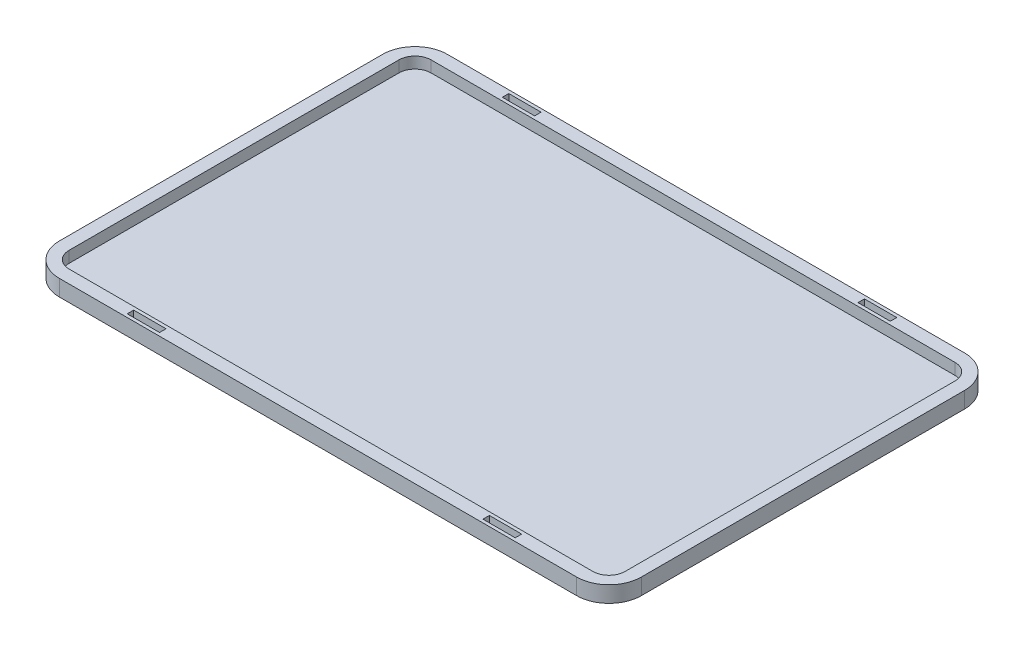
from build123d import *

# Parameters (mm, degrees)
SKETCH1_W           = 180
SKETCH1_H           = 120
BOSS_EXTRUDE1_DEPTH = 5
FILLET1_R           = 10
FILLET2_R           = 10
FILLET3_R           = 10
FILLET4_R           = 10
SHELL1_T            = -4
SKETCH6_W           = 172
SKETCH6_H           = 112
CUT_EXTRUDE1_DEPTH  = 8.5
FILLET5_R           = 5
FILLET6_R           = 5
FILLET7_R           = 5
FILLET8_R           = 5
SKETCH8_W           = 10
SKETCH8_H           = 2
CUT_EXTRUDE2_DEPTH  = 8


with BuildPart() as part:
    # Sketch1 → Boss-Extrude1 (new body)
    with BuildSketch(Plane(origin=(0, 0, 0), x_dir=(1, 0, 0), z_dir=(0, 1, 0))):
        Rectangle(SKETCH1_W, SKETCH1_H)
    extrude(amount=BOSS_EXTRUDE1_DEPTH)

    # Fillet1
    fillet1_edges = [part.edges().sort_by_distance(p)[0] for p in [
        (-90, 2.5, 60),
    ]]
    fillet(fillet1_edges, radius=FILLET1_R)

    # Fillet2
    fillet2_edges = [part.edges().sort_by_distance(p)[0] for p in [
        (90, 2.5, 60),
    ]]
    fillet(fillet2_edges, radius=FILLET2_R)

    # Fillet3
    fillet3_edges = [part.edges().sort_by_distance(p)[0] for p in [
        (90, 2.5, -60),
    ]]
    fillet(fillet3_edges, radius=FILLET3_R)

    # Fillet4
    fillet4_edges = [part.edges().sort_by_distance(p)[0] for p in [
        (-90, 2.5, -60),
    ]]
    fillet(fillet4_edges, radius=FILLET4_R)

    # Shell1
    shell1_openings = [part.faces().sort_by_distance(p)[0] for p in [
        (0, 5, 0),
    ]]
    offset(amount=SHELL1_T, openings=shell1_openings, kind=Kind.INTERSECTION)

    # Sketch6 → Cut-Extrude1 (cut)
    with BuildSketch(Plane(origin=(0, 10, 0), x_dir=(1, 0, 0), z_dir=(0, 1, 0))):
        Rectangle(SKETCH6_W, SKETCH6_H)
    extrude(amount=-CUT_EXTRUDE1_DEPTH, mode=Mode.SUBTRACT)

    # Fillet5
    fillet5_edges = [part.edges().sort_by_distance(p)[0] for p in [
        (-86, 3.25, -56),
    ]]
    fillet(fillet5_edges, radius=FILLET5_R)

    # Fillet6
    fillet6_edges = [part.edges().sort_by_distance(p)[0] for p in [
        (86, 3.25, -56),
    ]]
    fillet(fillet6_edges, radius=FILLET6_R)

    # Fillet7
    fillet7_edges = [part.edges().sort_by_distance(p)[0] for p in [
        (-86, 3.25, 56),
    ]]
    fillet(fillet7_edges, radius=FILLET7_R)

    # Fillet8
    fillet8_edges = [part.edges().sort_by_distance(p)[0] for p in [
        (86, 3.25, 56),
    ]]
    fillet(fillet8_edges, radius=FILLET8_R)

    # Sketch8 → Cut-Extrude2 (cut)
    with BuildSketch(Plane(origin=(0, 0, 0), x_dir=(1, 0, 0), z_dir=(0, 1, 0))):
        with Locations((-55, 58)):
            Rectangle(SKETCH8_W, SKETCH8_H)
        with Locations((55, 58)):
            Rectangle(SKETCH8_W, SKETCH8_H)
        with Locations((55, -58)):
            Rectangle(SKETCH8_W, SKETCH8_H)
        with Locations((-55, -58)):
            Rectangle(SKETCH8_W, SKETCH8_H)
    extrude(amount=CUT_EXTRUDE2_DEPTH, mode=Mode.SUBTRACT)


solid = part.part
